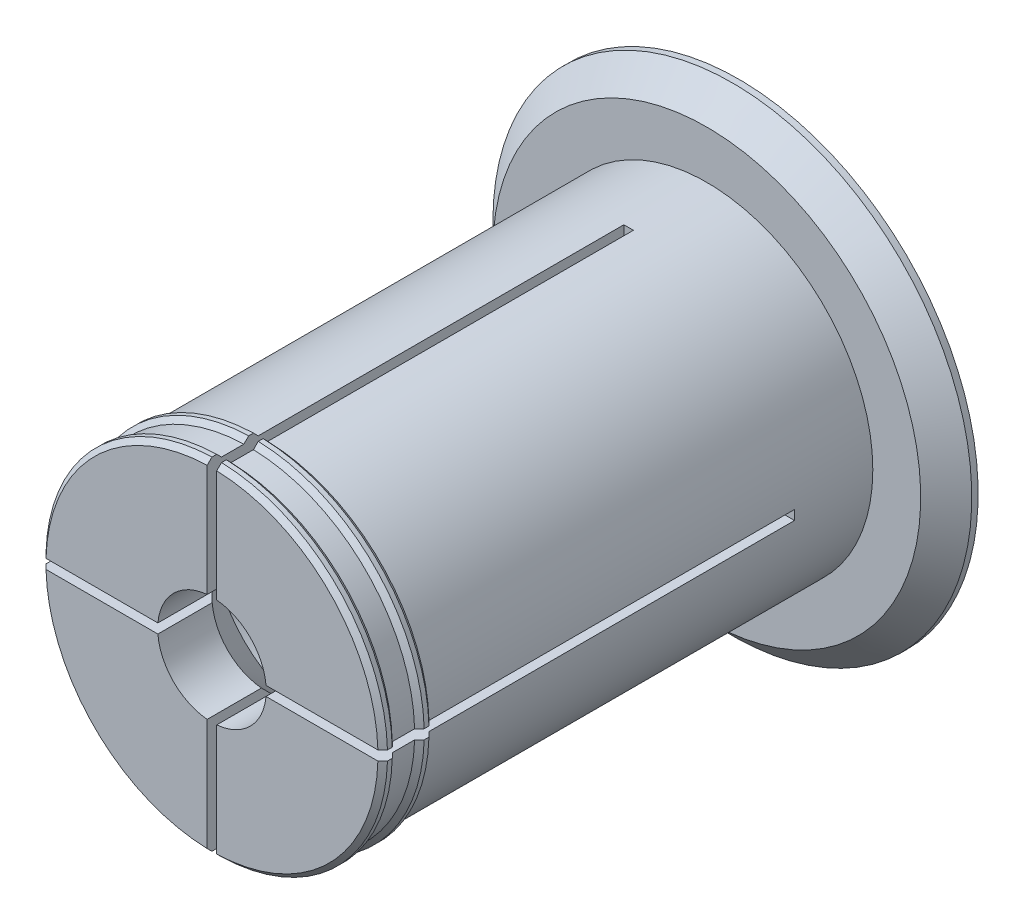
from build123d import *

# Parameters (mm, degrees)
AXLE_BASE_SKETCH_R        = 26
AXLE_DEPTH                = 77.5
GUARD_BASE_R              = 37.5
GUARD_DEPTH               = 5
INNER_AXLE_HOLE_BASE_R    = 8.5
INNER_AXLE_HOLE_DEPTH     = 83.5
BEND_START                = -65.25
BEND_ROOM_BASE_W          = 1.5
BEND_ROOM_BASE_H          = 75
BEND_ROOM_1_DEPTH         = 65.25
BEND_ROOM_2_COUNT         = 2
BEND_ROOM_2_ANGLE         = 90
EASY_REMOVAL_CHAMFER_SIZE = 4


with BuildPart() as part:
    # Axle base sketch → Axle (new body)
    with BuildSketch(Plane.XY):
        Circle(AXLE_BASE_SKETCH_R)
    extrude(amount=AXLE_DEPTH)

    # Guard base → Guard (add)
    with BuildSketch(Plane(origin=(0, 0, 0), x_dir=(-1, 0, 0), z_dir=(0, 0, -1))):
        Circle(GUARD_BASE_R)
    extrude(amount=GUARD_DEPTH)

    # Inner axle hole base → Inner axle hole (cut, through all)
    with BuildSketch(Plane.XY.offset(77.5)):
        Circle(INNER_AXLE_HOLE_BASE_R)
    extrude(amount=-INNER_AXLE_HOLE_DEPTH, mode=Mode.SUBTRACT)

    # Mate ring base → Mate rings (revolve)
    with BuildSketch(Plane(origin=(0, 0, 0), x_dir=(1, 0, 0), z_dir=(0, 1, 0))):
        Polygon((26, -77.5), (26.75, -76.75), (26.75, -76), (26, -75.25), align=None)
        Polygon((26, -71.75), (26.75, -71), (26.75, -70.25), (26, -69.5), align=None)
    revolve(axis=Axis((0, 0, 0), (0, 0, -1)))

    # Inner mass remove base → Inner mass remove (revolve, cut)
    with BuildSketch(Plane(origin=(0, 0, 0), x_dir=(0, 0, -1), z_dir=(1, 0, 0))):
        Polygon((-77.5, 0), (-60.25, -17.25), (-12.25, -17.25), (5, 0), align=None)
    revolve(axis=Axis((0, 0, 0), (0, 0, -1)), mode=Mode.SUBTRACT)

    # Bend room base → Bend room 1 (cut)
    with BuildSketch(Plane.XY.offset(77.5).offset(BEND_START)):
        Rectangle(BEND_ROOM_BASE_W, BEND_ROOM_BASE_H)
    bend_room_1 = extrude(amount=BEND_ROOM_1_DEPTH, mode=Mode.SUBTRACT)

    # Bend room 2: Bend room 1 ×2 about axis
    bend_room_2_axis = Axis((0, 0, 0), (0, 0, -1))
    for i in range(1, BEND_ROOM_2_COUNT):
        add(bend_room_1.rotate(bend_room_2_axis, i * BEND_ROOM_2_ANGLE / (BEND_ROOM_2_COUNT - 1)), mode=Mode.SUBTRACT)

    # Easy removal chamfer
    easy_removal_chamfer_edges = [part.edges().sort_by_distance(p)[0] for p in [
        (37.5, 0, 0),
    ]]
    chamfer(easy_removal_chamfer_edges, length=EASY_REMOVAL_CHAMFER_SIZE)


solid = part.part
